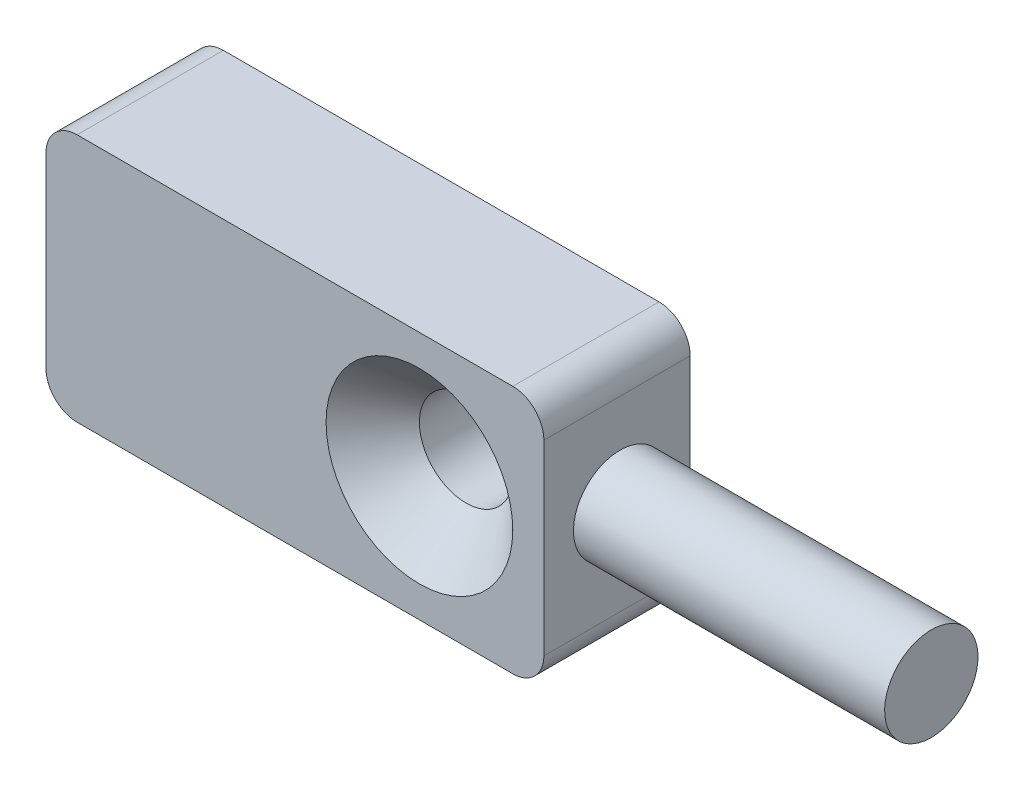
from build123d import *

# Parameters (mm, degrees)
SKIZZE1_W                       = 16
SKIZZE1_H                       = 8
SKIZZE1_R                       = 1.5
AUFSATZ_LINEAR_AUSTRAGEN1_DEPTH = 4.7
VERRUNDUNG1_R                   = 1
FASE1_SIZE                      = 1.5
SKIZZE2_R                       = 1.5
AUFSATZ_LINEAR_AUSTRAGEN2_DEPTH = 10


with BuildPart() as part:
    # Skizze1 → Aufsatz-Linear austragen1 (new body)
    with BuildSketch(Plane.XY):
        with Locations((-8, 0)):
            Rectangle(SKIZZE1_W, SKIZZE1_H)
        with Locations((-4, 0)):
            Circle(SKIZZE1_R, mode=Mode.SUBTRACT)
    extrude(amount=AUFSATZ_LINEAR_AUSTRAGEN1_DEPTH)

    # Verrundung1
    verrundung1_edges = [part.edges().sort_by_distance(p)[0] for p in [
        (0, -4, 2.35),
        (-16, -4, 2.35),
        (-16, 4, 2.35),
        (0, 4, 2.35),
    ]]
    fillet(verrundung1_edges, radius=VERRUNDUNG1_R)

    # Fase1
    fase1_edges = [part.edges().sort_by_distance(p)[0] for p in [
        (-5.5, 0, 4.7),
    ]]
    chamfer(fase1_edges, length=FASE1_SIZE)

    # Skizze2 → Aufsatz-Linear austragen2 (add)
    with BuildSketch(Plane(origin=(0, 0, 0), x_dir=(0, 0, -1), z_dir=(1, 0, 0))):
        with Locations((-2.25, 0)):
            Circle(SKIZZE2_R)
    extrude(amount=AUFSATZ_LINEAR_AUSTRAGEN2_DEPTH)


solid = part.part
